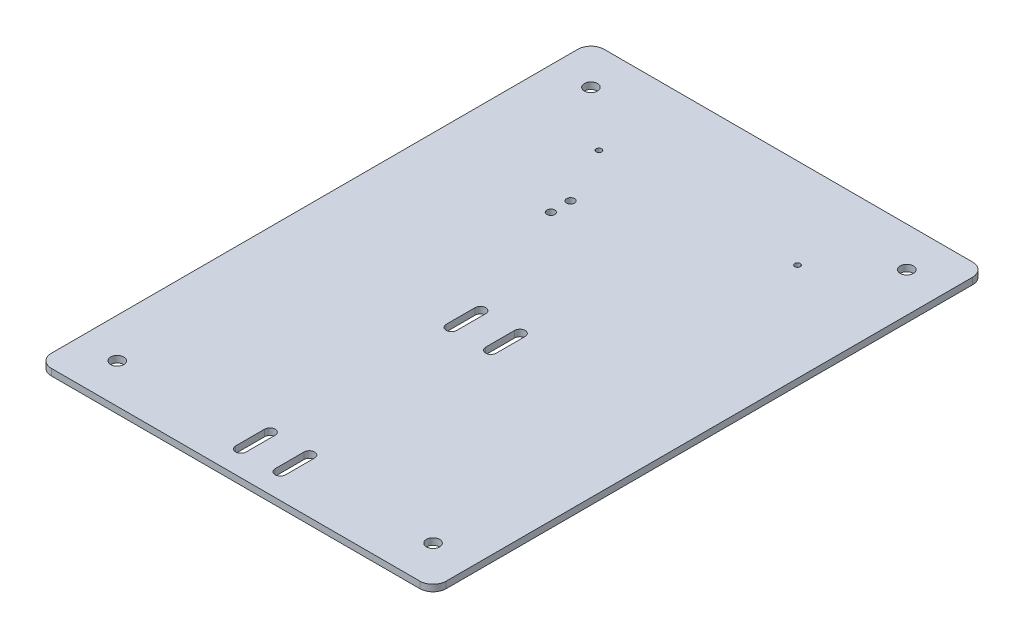
from build123d import *

# Parameters (mm, degrees)
SKIZZE2_W                            = 300
SKIZZE2_H                            = 5
AUFSATZ_LINEAR_AUSTRAGEN1_DEPTH      = 300
AUFSATZ_LINEAR_AUSTRAGEN1_DEPTH_BACK = 120
SCHNITT_LINEAR_AUSTRAGEN1_DEPTH      = 5
SKIZZE6_R                            = 3
SCHNITT_LINEAR_AUSTRAGEN2_DEPTH      = 5
SKIZZE8_R                            = 5
SCHNITT_LINEAR_AUSTRAGEN3_DEPTH      = 21
VERRUNDUNG1_R                        = 10
SKIZZE9_R                            = 2.1
SCHNITT_LINEAR_AUSTRAGEN4_DEPTH      = 5


with BuildPart() as part:
    # Skizze2 → Aufsatz-Linear austragen1 (new body, two sides)
    with BuildSketch(Plane.XY) as aufsatz_linear_austragen1_sk:
        with Locations((0, -18.5)):
            Rectangle(SKIZZE2_W, SKIZZE2_H)
    extrude(amount=AUFSATZ_LINEAR_AUSTRAGEN1_DEPTH)
    extrude(aufsatz_linear_austragen1_sk.sketch, amount=-AUFSATZ_LINEAR_AUSTRAGEN1_DEPTH_BACK)

    # Skizze4 → Schnitt-Linear austragen1 (cut)
    with BuildSketch(Plane(origin=(0, -16, 0), x_dir=(1, 0, 0), z_dir=(0, 1, 0))):
        with BuildLine():
            Line((-19, -121), (-19, -99))
            ThreePointArc((-19, -99), (-15, -95), (-11, -99))
            Line((-11, -99), (-11, -121))
            ThreePointArc((-11, -121), (-15, -125), (-19, -121))
        make_face()
        with BuildLine():
            Line((19, -121), (19, -99))
            ThreePointArc((19, -99), (15, -95), (11, -99))
            Line((11, -99), (11, -121))
            ThreePointArc((11, -121), (15, -125), (19, -121))
        make_face()
        with BuildLine():
            Line((-19, -259), (-19, -281))
            ThreePointArc((-19, -281), (-15, -285), (-11, -281))
            Line((-11, -281), (-11, -259))
            ThreePointArc((-11, -259), (-15, -255), (-19, -259))
        make_face()
        with BuildLine():
            Line((19, -259), (19, -281))
            ThreePointArc((19, -281), (15, -285), (11, -281))
            Line((11, -281), (11, -259))
            ThreePointArc((11, -259), (15, -255), (19, -259))
        make_face()
    extrude(amount=-SCHNITT_LINEAR_AUSTRAGEN1_DEPTH, mode=Mode.SUBTRACT)

    # Skizze6 → Schnitt-Linear austragen2 (cut)
    with BuildSketch(Plane(origin=(0, -16, 0), x_dir=(1, 0, 0), z_dir=(0, 1, 0))):
        with Locations((-53, 7.5)):
            Circle(SKIZZE6_R)
        with Locations((-53, -7.5)):
            Circle(SKIZZE6_R)
    extrude(amount=-SCHNITT_LINEAR_AUSTRAGEN2_DEPTH, mode=Mode.SUBTRACT)

    # Skizze8 → Schnitt-Linear austragen3 (cut)
    with BuildSketch(Plane(origin=(0, 0, 0), x_dir=(1, 0, 0), z_dir=(0, 1, 0))):
        with Locations((-120, 90)):
            Circle(SKIZZE8_R)
        with Locations((120, 90)):
            Circle(SKIZZE8_R)
        with Locations((120, -270)):
            Circle(SKIZZE8_R)
        with Locations((-120, -270)):
            Circle(SKIZZE8_R)
    extrude(amount=-SCHNITT_LINEAR_AUSTRAGEN3_DEPTH, mode=Mode.SUBTRACT)

    # Verrundung1
    verrundung1_edges = [part.edges().sort_by_distance(p)[0] for p in [
        (-150, -18.5, -120),
        (150, -18.5, -120),
        (150, -18.5, 300),
        (-150, -18.5, 300),
    ]]
    fillet(verrundung1_edges, radius=VERRUNDUNG1_R)

    # Skizze9 → Schnitt-Linear austragen4 (cut)
    with BuildSketch(Plane(origin=(0, -16, 0), x_dir=(1, 0, 0), z_dir=(0, 1, 0))):
        with Locations((75.5, 51.5)):
            Circle(SKIZZE9_R)
        with Locations((-75.5, 51.5)):
            Circle(SKIZZE9_R)
    extrude(amount=-SCHNITT_LINEAR_AUSTRAGEN4_DEPTH, mode=Mode.SUBTRACT)


solid = part.part
